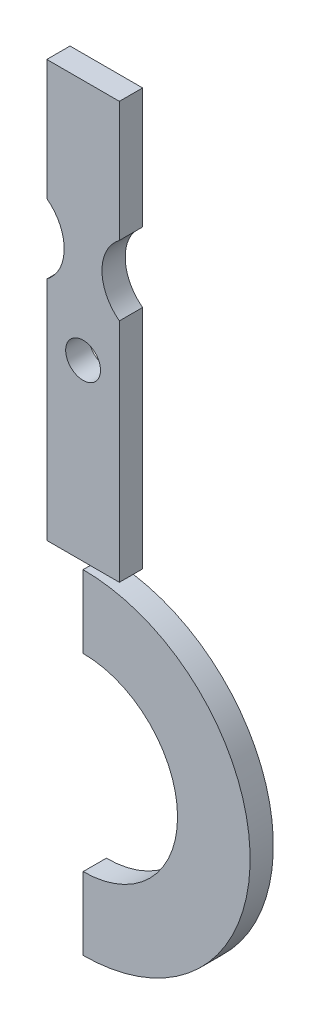
from build123d import *

# Parameters (mm, degrees)
SKETCH1_R             = 6
BOSS_EXTRUDE1_DEPTH   = 8
BOSS_EXTRUDE1_2_DEPTH = 8


with BuildPart() as part:
    # Sketch1 → Boss-Extrude1 (new body)
    with BuildSketch(Plane.XY):
        with BuildLine():
            Line((-12.5, -13.638181697), (-12.5, -23))
            ThreePointArc((-12.5, -23), (-6.5, -35), (-12.5, -47))
            Line((-12.5, -47), (-12.5, -125))
            Line((-12.5, -125), (12.5, -125))
            Line((12.5, -125), (12.5, -47))
            ThreePointArc((12.5, -47), (6.5, -35), (12.5, -23))
            Line((12.5, -23), (12.5, -13.638181697))
            Line((12.5, -13.638181697), (12.5, 18.5))
            Line((12.5, 18.5), (-12.5, 18.5))
            Line((-12.5, 18.5), (-12.5, -13.638181697))
        make_face()
        with Locations((0, -65)):
            Circle(SKETCH1_R, mode=Mode.SUBTRACT)
    extrude(amount=BOSS_EXTRUDE1_DEPTH)


with BuildPart() as body_2:
    # Sketch1 → Boss-Extrude1 2 (new body)
    with BuildSketch(Plane.XY):
        with BuildLine():
            Line((0, -127.456671403), (0, -152.456671403))
            ThreePointArc((0, -152.456671403), (32.543328597, -185), (0, -217.543328597))
            Line((0, -217.543328597), (0, -242.543328597))
            ThreePointArc((0, -242.543328597), (57.543328597, -185), (0, -127.456671403))
        make_face()
    extrude(amount=BOSS_EXTRUDE1_2_DEPTH)


solid = Compound([part.part, body_2.part])
